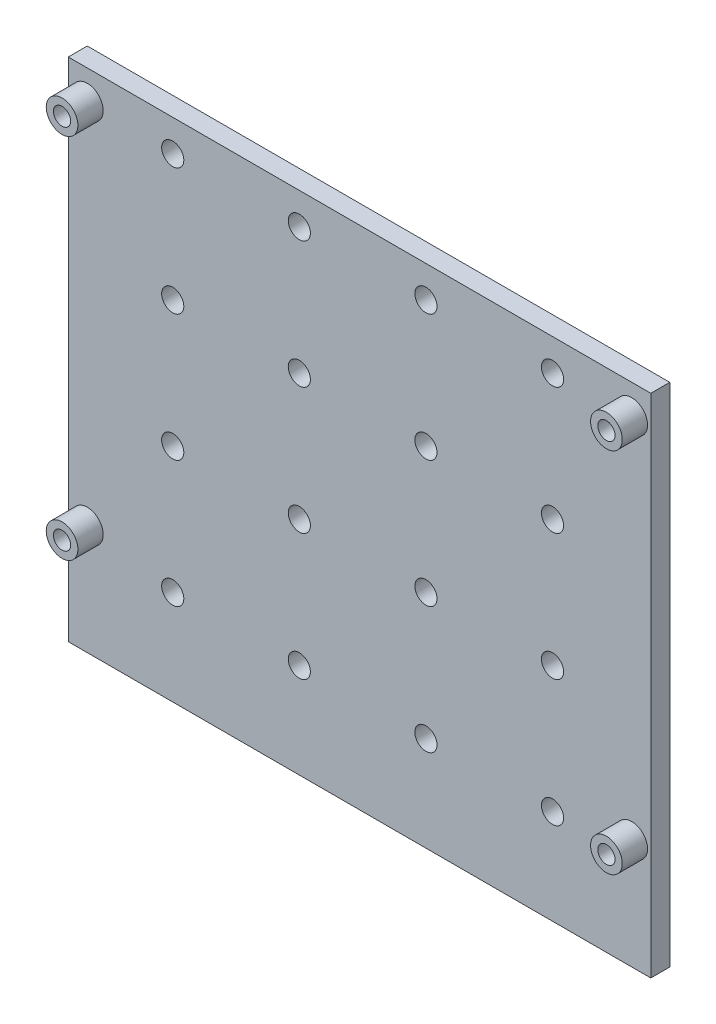
from build123d import *

# Parameters (mm, degrees)
SKETCH1_W            = 92.024962686
SKETCH1_H            = 80
SKETCH1_R            = 1.365
BOSS_EXTRUDE1_DEPTH  = 3
SKETCH3_R            = 2.5
SKETCH3_R_2          = 1.365
BOSS_EXTRUDE2_DEPTH  = 4
CUT_EXTRUDE2_START   = -4
SKETCH4_R            = 1.75
CUT_EXTRUDE2_DEPTH   = 9
LPATTERN1_COUNT      = 4
LPATTERN1_PITCH      = 20
LPATTERN1_COUNT_DIR2 = 4
LPATTERN1_PITCH_DIR2 = 20


with BuildPart() as part:
    # Sketch1 → Boss-Extrude1 (new body)
    with BuildSketch(Plane.XY):
        Rectangle(SKETCH1_W, SKETCH1_H)
        with Locations((-42.997518657, 35.4)):
            Circle(SKETCH1_R, mode=Mode.SUBTRACT)
        with Locations((43.002481343, 35.4)):
            Circle(SKETCH1_R, mode=Mode.SUBTRACT)
        with Locations((-42.997518657, -22.6)):
            Circle(SKETCH1_R, mode=Mode.SUBTRACT)
        with Locations((43.002481343, -22.6)):
            Circle(SKETCH1_R, mode=Mode.SUBTRACT)
    extrude(amount=BOSS_EXTRUDE1_DEPTH)

    # Sketch3 → Boss-Extrude2 (add)
    with BuildSketch(Plane.XY.offset(3)):
        with Locations((-42.997518657, 35.4)):
            Circle(SKETCH3_R)
        with Locations((-42.997518657, 35.4)):
            Circle(SKETCH3_R_2, mode=Mode.SUBTRACT)
        with Locations((-42.997518657, -22.6)):
            Circle(SKETCH3_R)
        with Locations((-42.997518657, -22.6)):
            Circle(SKETCH3_R_2, mode=Mode.SUBTRACT)
        with Locations((43.002481343, 35.4)):
            Circle(SKETCH3_R)
        with Locations((43.002481343, 35.4)):
            Circle(SKETCH3_R_2, mode=Mode.SUBTRACT)
        with Locations((43.002481343, -22.6)):
            Circle(SKETCH3_R)
        with Locations((43.002481343, -22.6)):
            Circle(SKETCH3_R_2, mode=Mode.SUBTRACT)
    extrude(amount=BOSS_EXTRUDE2_DEPTH)

    # Sketch4 → Cut-Extrude2 (cut)
    with BuildSketch(Plane.XY.offset(3).offset(CUT_EXTRUDE2_START)):
        with Locations((-29.512481343, 35)):
            Circle(SKETCH4_R)
    cut_extrude2 = extrude(amount=CUT_EXTRUDE2_DEPTH, mode=Mode.SUBTRACT)

    # LPattern1: Cut-Extrude2 4 × 4
    with Locations(*[(i * LPATTERN1_PITCH, -j * LPATTERN1_PITCH_DIR2, 0) for i in range(LPATTERN1_COUNT) for j in range(LPATTERN1_COUNT_DIR2) if (i, j) != (0, 0)]):
        add(cut_extrude2, mode=Mode.SUBTRACT)


solid = part.part
